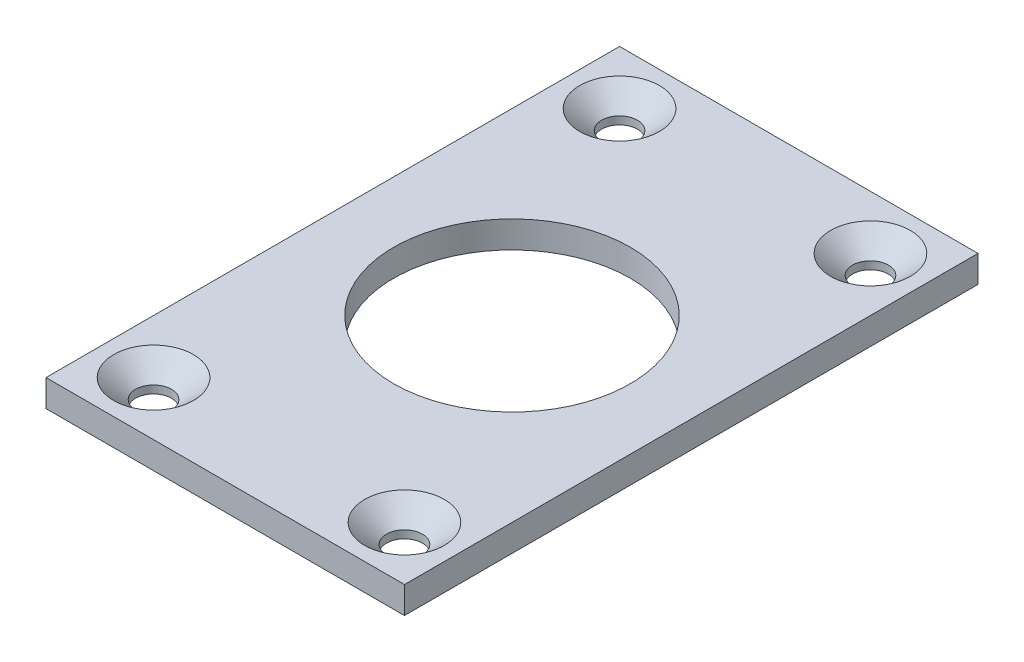
from build123d import *

# Parameters (mm, degrees)
SKETCH1_W           = 63.5
SKETCH1_H           = 101.6
SKETCH1_R           = 20.955
SKETCH1_R_2         = 3.175
BOSS_EXTRUDE1_DEPTH = 4.7625
CHAMFER1_SIZE       = 3.8862
CHAMFER1_SIZE2      = 3.378222121


with BuildPart() as part:
    # Sketch1 → Boss-Extrude1 (new body)
    with BuildSketch(Plane(origin=(0, 0, 0), x_dir=(1, 0, 0), z_dir=(0, 1, 0))):
        with Locations((31.75, 50.8)):
            Rectangle(SKETCH1_W, SKETCH1_H)
        with Locations((31.75, 50.8)):
            Circle(SKETCH1_R, mode=Mode.SUBTRACT)
        with Locations((9.525, 92.075)):
            Circle(SKETCH1_R_2, mode=Mode.SUBTRACT)
        with Locations((53.975, 92.075)):
            Circle(SKETCH1_R_2, mode=Mode.SUBTRACT)
        with Locations((53.975, 9.525)):
            Circle(SKETCH1_R_2, mode=Mode.SUBTRACT)
        with Locations((9.525, 9.525)):
            Circle(SKETCH1_R_2, mode=Mode.SUBTRACT)
    extrude(amount=BOSS_EXTRUDE1_DEPTH)

    # Chamfer1
    chamfer1_edges = [part.edges().sort_by_distance(p)[0] for p in [
        (6.35, 4.7625, -92.075),
        (50.8, 4.7625, -92.075),
        (50.8, 4.7625, -9.525),
        (6.35, 4.7625, -9.525),
    ]]
    chamfer1_side = [part.faces().sort_by_distance(p)[0] for p in [
        (31.75, 4.7625, -1.198115604),
    ]]
    chamfer(chamfer1_edges, length=CHAMFER1_SIZE, length2=CHAMFER1_SIZE2, reference=chamfer1_side[0])


solid = part.part
